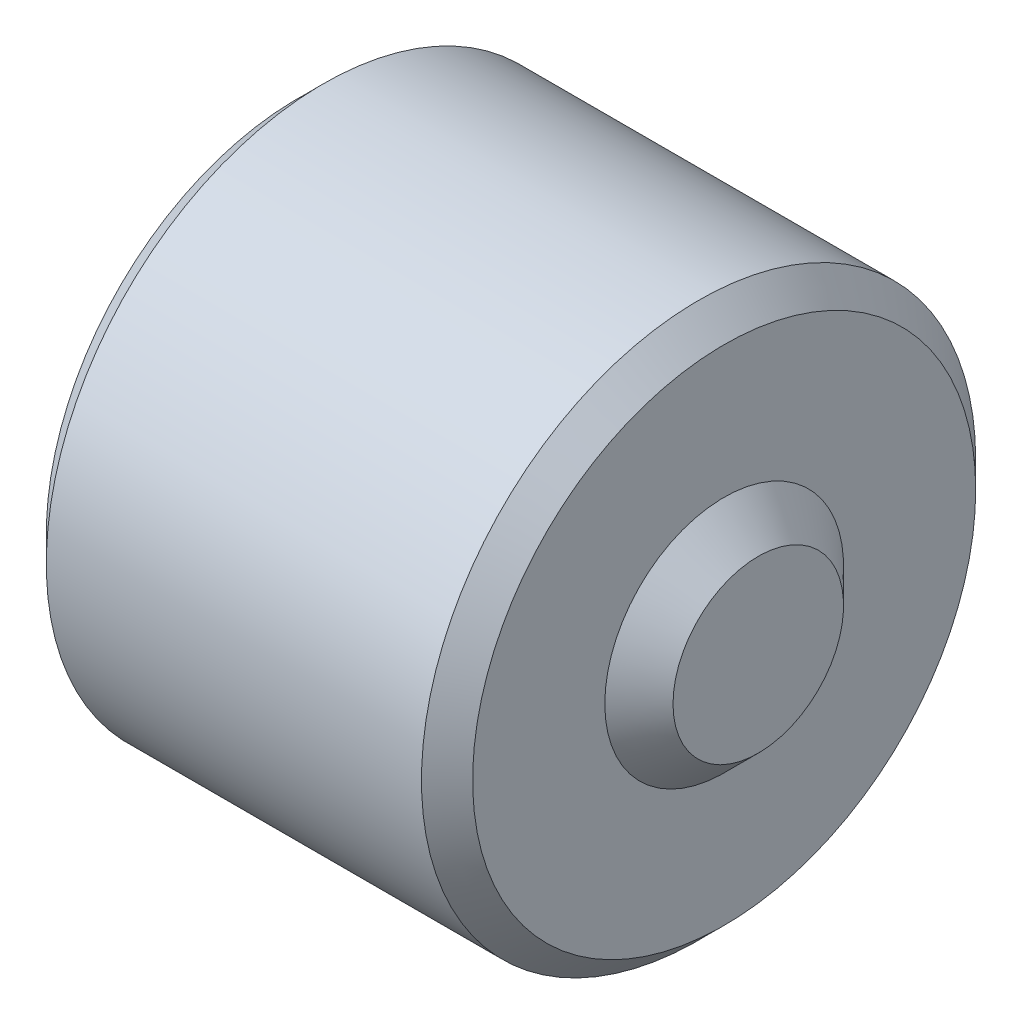
from build123d import *

# Parameters (mm, degrees)
SKETCH1_R           = 8.255
BOSS_EXTRUDE1_DEPTH = 12.7
SKETCH2_R           = 5.715
CUT_EXTRUDE1_DEPTH  = 10.16
CHAMFER1_SIZE       = 0.762


with BuildPart() as part:
    # Sketch1 → Boss-Extrude1 (new body)
    with BuildSketch(Plane(origin=(0, 0, 0), x_dir=(0, 0, -1), z_dir=(1, 0, 0))):
        Circle(SKETCH1_R)
    extrude(amount=-BOSS_EXTRUDE1_DEPTH)

    # Sketch2 → Cut-Extrude1 (cut)
    with BuildSketch(Plane.ZY.offset(12.7)):
        Circle(SKETCH2_R)
    extrude(amount=-CUT_EXTRUDE1_DEPTH, mode=Mode.SUBTRACT)

    # Chamfer1
    chamfer1_edges = [part.edges().sort_by_distance(p)[0] for p in [
        (0, 0, 8.255),
        (-12.7, 0, 8.255),
    ]]
    chamfer(chamfer1_edges, length=CHAMFER1_SIZE)

    # Sketch3 → Revolve1 (revolve)
    with BuildSketch(Plane(origin=(0, 0, 0), x_dir=(1, 0, 0), z_dir=(0, 1, 0))):
        Polygon((0, 0), (1.016, 0), (1.016, 2.54), (0, 3.556), align=None)
    revolve(axis=Axis((-11.938, 0, 0), (1, 0, 0)))


solid = part.part
